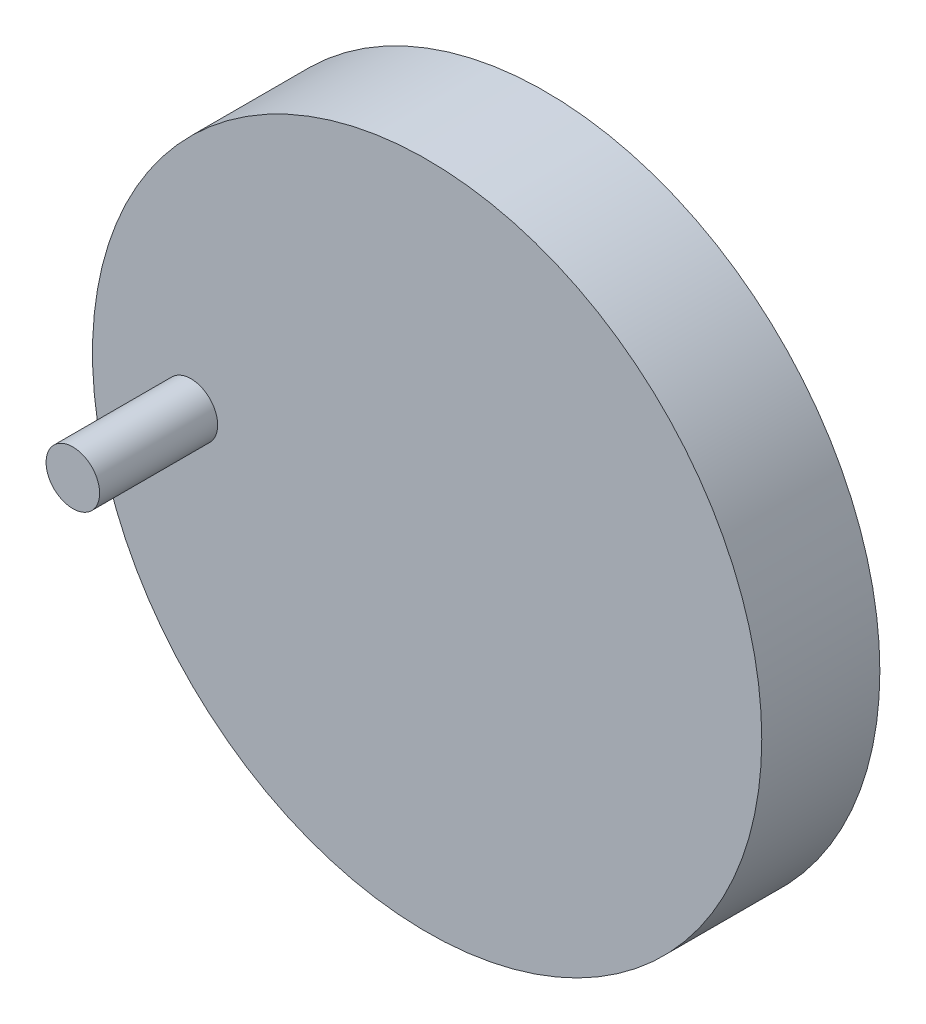
from build123d import *

# Parameters (mm, degrees)
SKETCH1_R           = 28.337466136
SKETCH1_R_2         = 2.266997291
BOSS_EXTRUDE1_DEPTH = 10
SKETCH1_2_R         = 2.266997291
BOSS_EXTRUDE2_DEPTH = 10
SKETCH1_4_R         = 2.266997291
BOSS_EXTRUDE3_DEPTH = 20


with BuildPart() as part:
    # Sketch1 → Boss-Extrude1 (new body)
    with BuildSketch(Plane.XY):
        Circle(SKETCH1_R)
        Circle(SKETCH1_R_2, mode=Mode.SUBTRACT)
        with Locations((-20, 0)):
            Circle(SKETCH1_R_2, mode=Mode.SUBTRACT)
    extrude(amount=BOSS_EXTRUDE1_DEPTH)

    # Sketch1_2 → Boss-Extrude2 (add, symmetric)
    with BuildSketch(Plane.XY):
        Circle(SKETCH1_2_R)
    extrude(amount=BOSS_EXTRUDE2_DEPTH, both=True)

    # Sketch1_4 → Boss-Extrude3 (add)
    with BuildSketch(Plane.XY):
        with Locations((-20, 0)):
            Circle(SKETCH1_4_R)
    extrude(amount=BOSS_EXTRUDE3_DEPTH)


solid = part.part
